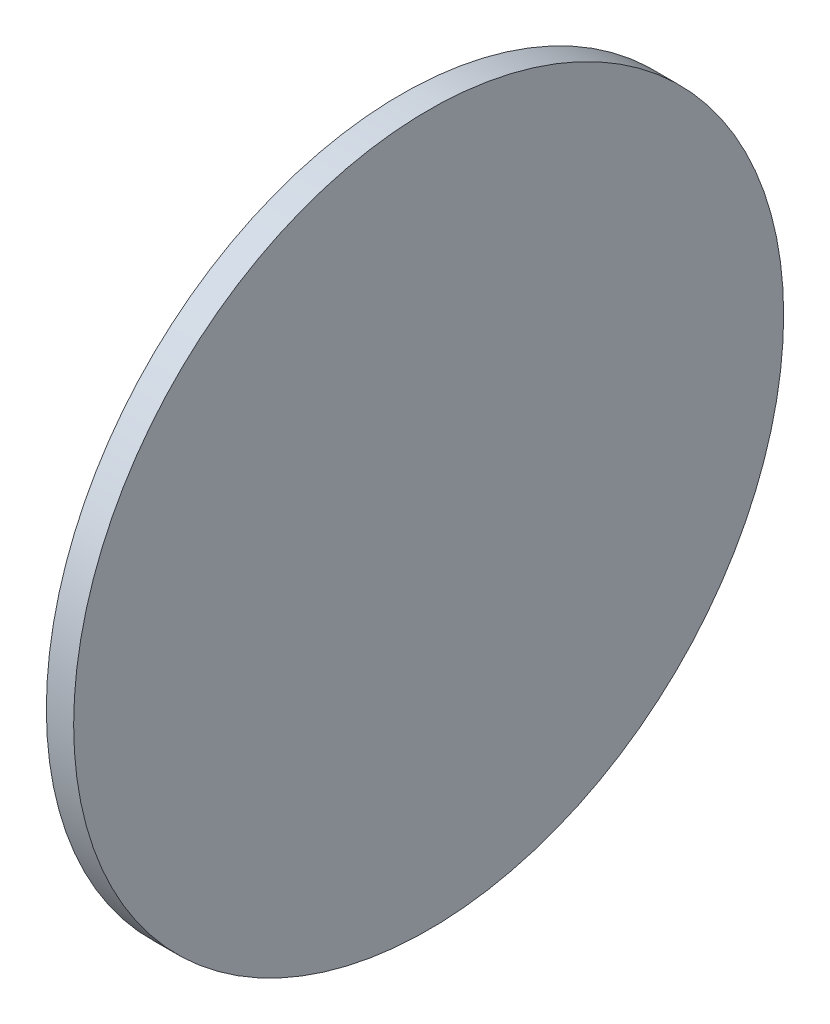
from build123d import *

# Parameters (mm, degrees)
SKETCH1_R           = 330.2
BOSS_EXTRUDE1_DEPTH = 25.4


with BuildPart() as part:
    # Sketch1 → Boss-Extrude1 (new body)
    with BuildSketch(Plane(origin=(0, 0, 0), x_dir=(0, 0, -1), z_dir=(1, 0, 0))):
        Circle(SKETCH1_R)
    extrude(amount=BOSS_EXTRUDE1_DEPTH)


solid = part.part
